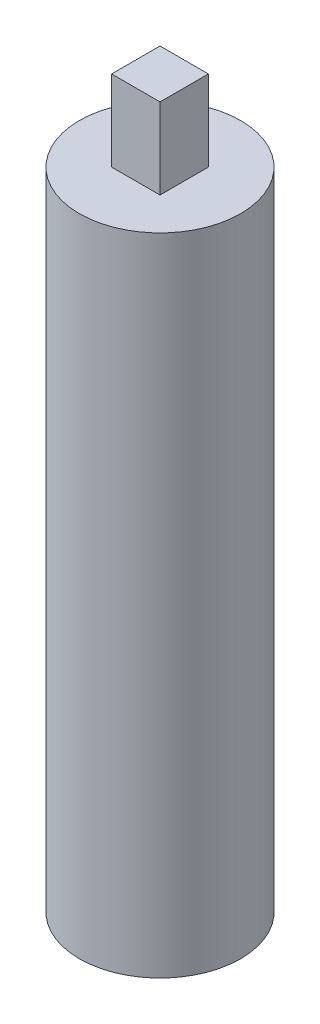
from build123d import *

# Parameters (mm, degrees)
SKETCH1_R           = 5
BOSS_EXTRUDE1_DEPTH = 40
SKETCH2_W           = 3
SKETCH2_H           = 3
BOSS_EXTRUDE2_DEPTH = 5


with BuildPart() as part:
    # Sketch1 → Boss-Extrude1 (new body)
    with BuildSketch(Plane(origin=(0, 0, 0), x_dir=(1, 0, 0), z_dir=(0, 1, 0))):
        Circle(SKETCH1_R)
    extrude(amount=BOSS_EXTRUDE1_DEPTH)

    # Sketch2 → Boss-Extrude2 (add)
    with BuildSketch(Plane(origin=(0, 40, 0), x_dir=(1, 0, 0), z_dir=(0, 1, 0))):
        Rectangle(SKETCH2_W, SKETCH2_H)
    extrude(amount=BOSS_EXTRUDE2_DEPTH)


solid = part.part
